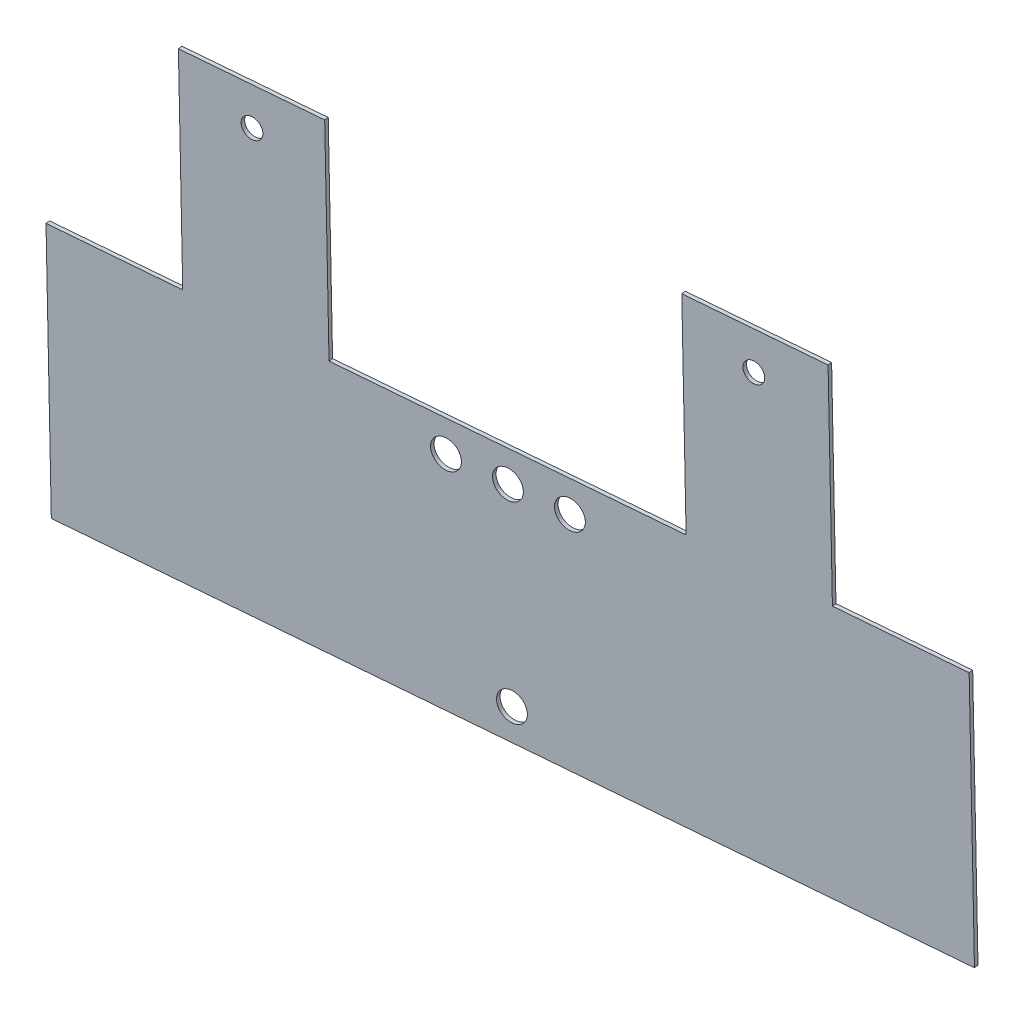
from build123d import *

# Parameters (mm, degrees)
BOSS_EXTRUDE1_DEPTH = 0.6096
SKETCH5_R           = 2.25
CUT_EXTRUDE2_DEPTH  = 430.420105
SKETCH6_R           = 1.5875
CUT_EXTRUDE5_DEPTH  = 0.6096
SKETCH7_R           = 1.5875
CUT_EXTRUDE6_DEPTH  = 0.6096
SKETCH8_R           = 2.25
CUT_EXTRUDE7_DEPTH  = 2.54


with BuildPart() as part:
    # Sketch1 → Boss-Extrude1 (new body)
    with BuildSketch(Plane(origin=(16.997226787, -4.149929847, 204.631375634), x_dir=(0.99656941, 0.00195951, -0.082737969), z_dir=(-0.082760694, 0.020206301, -0.996364578))):
        Polygon((-405.631572024, 283.216979703), (-385.692572024, 283.216979703), (-385.692572024, 323.856979703), (-405.014358213, 323.856979703), (-432.414358217, 323.856979703), (-445.097076418, 323.856979703), (-465.359895626, 323.856979703), (-479.498480719, 323.856979703), (-500.373572024, 323.856979703), (-520.312572024, 323.856979703), (-520.312572024, 283.216979703), (-500.373572024, 283.216979703), (-500.373572024, 250.003685703), (-479.037572024, 250.003685703), (-479.037572024, 283.216979703), (-426.967572024, 283.216979703), (-426.967572024, 250.003685703), (-405.631572024, 250.003685703), align=None)
    extrude(amount=BOSS_EXTRUDE1_DEPTH)

    # Sketch5 → Cut-Extrude2 (cut)
    with BuildSketch(Plane(origin=(16.946775868, -4.137612086, 204.023991787), x_dir=(-0.996569449, -0.001678044, 0.082743681), z_dir=(-0.082760694, 0.020206301, -0.996364578))):
        with Locations((452.956635294, -318.984510283)):
            Circle(SKETCH5_R)
    cut_extrude2 = extrude(amount=-CUT_EXTRUDE2_DEPTH, mode=Mode.SUBTRACT)

    # Mirror1: Cut-Extrude2 across plane
    add(cut_extrude2.mirror(Plane(origin=(0.085159645, -303.474424262, -6.16154314), x_dir=(5.696e-06, -0.020299151, 0.999793951), z_dir=(0.000280558, -0.999793912, -0.020299152))), mode=Mode.SUBTRACT)

    # Sketch6 → Cut-Extrude5 (cut)
    with BuildSketch(Plane(origin=(16.946775868, -4.137612086, 204.023991787), x_dir=(-0.996569449, -0.001678044, 0.082743681), z_dir=(-0.082760694, 0.020206301, -0.996364578))):
        with Locations((416.50680125, -256.173836565)):
            Circle(SKETCH6_R)
    extrude(amount=-CUT_EXTRUDE5_DEPTH, mode=Mode.SUBTRACT)

    # Sketch7 → Cut-Extrude6 (cut)
    with BuildSketch(Plane(origin=(16.946775868, -4.137612086, 204.023991787), x_dir=(-0.996569449, -0.001678044, 0.082743681), z_dir=(-0.082760694, 0.020206301, -0.996364578))):
        with Locations((489.681466673, -256.194436956)):
            Circle(SKETCH7_R)
    extrude(amount=-CUT_EXTRUDE6_DEPTH, mode=Mode.SUBTRACT)

    # Sketch8 → Cut-Extrude7 (cut)
    with BuildSketch(Plane(origin=(16.997226787, -4.149929847, 204.631375634), x_dir=(0.996569449, 0.001678044, -0.082743681), z_dir=(0.082760694, -0.020206301, 0.996364578))):
        with Locations((-443.925718519, -288.341966658)):
            Circle(SKETCH8_R)
        with Locations((-960.270444462, 120.825542597)):
            Circle(SKETCH8_R)
        with Locations((-462.00480383, -288.347056346)):
            Circle(SKETCH8_R)
    extrude(amount=-CUT_EXTRUDE7_DEPTH, mode=Mode.SUBTRACT)


solid = part.part
